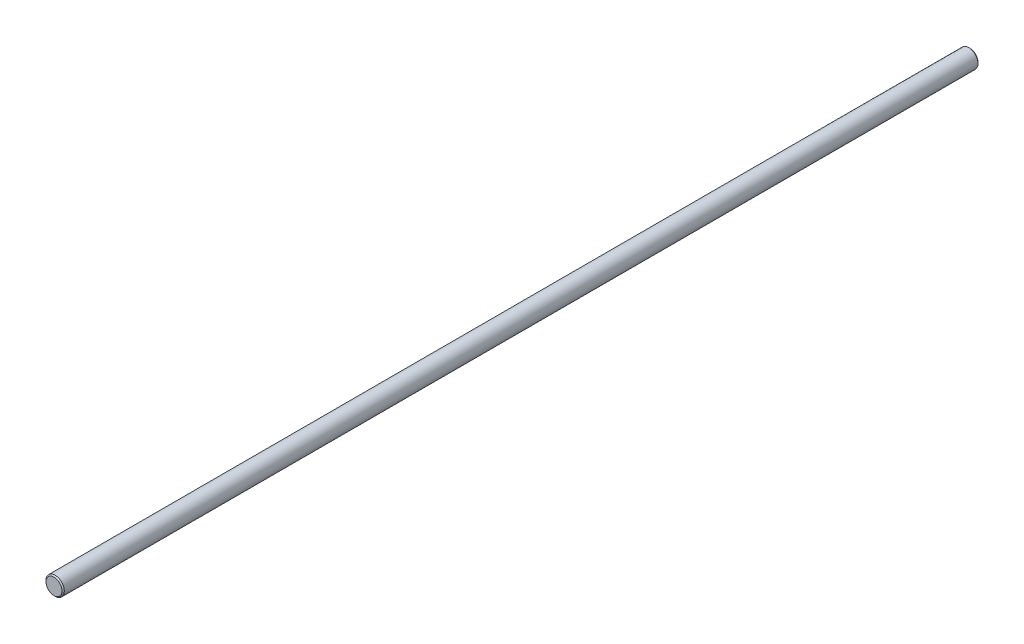
from build123d import *

# Parameters (mm, degrees)
ESQUISSE1_R        = 4
BOSS_EXTRU_1_DEPTH = 400
CHANFREIN1_SIZE    = 0.5


with BuildPart() as part:
    # Esquisse1 → Boss.-Extru.1 (new body)
    with BuildSketch(Plane.XY):
        Circle(ESQUISSE1_R)
    extrude(amount=BOSS_EXTRU_1_DEPTH)

    # Chanfrein1
    chanfrein1_edges = [part.edges().sort_by_distance(p)[0] for p in [
        (-4, 0, 0),
        (-4, 0, 400),
    ]]
    chamfer(chanfrein1_edges, length=CHANFREIN1_SIZE)


solid = part.part
